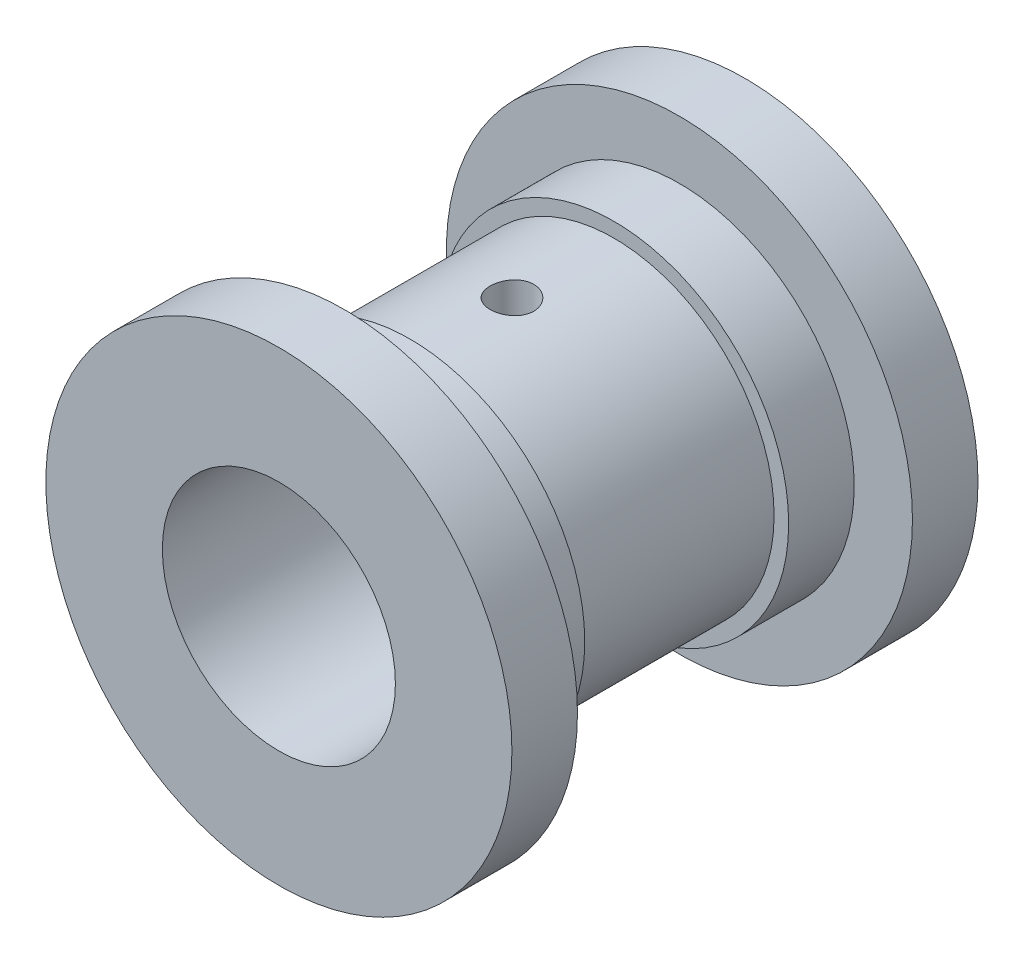
from build123d import *

# Parameters (mm, degrees)
SKETCH1_R           = 22
BOSS_EXTRUDE1_DEPTH = 14
SKETCH2_R           = 24
BOSS_EXTRUDE2_DEPTH = 9
SKETCH3_R           = 32
BOSS_EXTRUDE3_DEPTH = 9
SKETCH5_R           = 4
BOSS_EXTRUDE4_DEPTH = 30
CUT_EXTRUDE2_REACH  = 66
SKETCH4_R           = 16
SKETCH6_R           = 3
CUT_EXTRUDE3_DEPTH  = 63


with BuildPart() as part:
    # Sketch1 → Boss-Extrude1 (new body, symmetric)
    with BuildSketch(Plane.XY):
        Circle(SKETCH1_R)
    extrude(amount=BOSS_EXTRUDE1_DEPTH, both=True)

    # Sketch2 → Boss-Extrude2 (add)
    with BuildSketch(Plane.XY.offset(14)):
        Circle(SKETCH2_R)
    boss_extrude2 = extrude(amount=BOSS_EXTRUDE2_DEPTH)

    # Mirror1: Boss-Extrude2 across plane
    add(boss_extrude2.mirror(Plane.XY))

    # Sketch3 → Boss-Extrude3 (add)
    with BuildSketch(Plane.XY.offset(23)):
        Circle(SKETCH3_R)
    boss_extrude3 = extrude(amount=BOSS_EXTRUDE3_DEPTH)

    # Mirror2: Boss-Extrude3 across plane
    add(boss_extrude3.mirror(Plane.XY))

    # Sketch5 → Boss-Extrude4 (add)
    with BuildSketch(Plane(origin=(0, 0, 0), x_dir=(1, 0, 0), z_dir=(0, 1, 0))):
        Circle(SKETCH5_R)
    extrude(amount=-BOSS_EXTRUDE4_DEPTH)

    # Sketch4 → Cut-Extrude2 (cut, up to next)
    with BuildSketch(Plane.XY.offset(32), mode=Mode.PRIVATE) as cut_extrude2_sk1:
        Circle(SKETCH4_R)
    cut_extrude2_tool1 = extrude(cut_extrude2_sk1.sketch, amount=-CUT_EXTRUDE2_REACH, mode=Mode.PRIVATE) & part.part
    add(cut_extrude2_tool1.solids().sort_by_distance((0, 0, 32))[0], mode=Mode.SUBTRACT)

    # Sketch6 → Cut-Extrude3 (cut, through all)
    with BuildSketch(Plane.XZ.offset(30)):
        Circle(SKETCH6_R)
    extrude(amount=-CUT_EXTRUDE3_DEPTH, mode=Mode.SUBTRACT)


solid = part.part
